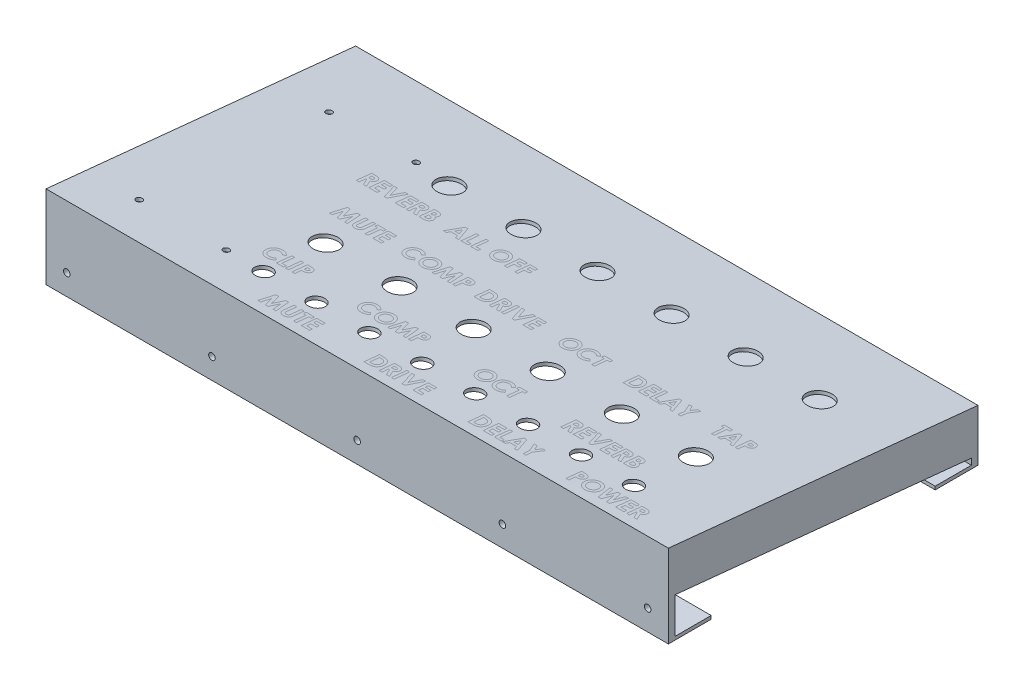
from build123d import *

# Parameters (mm, degrees)
BOSS_EXTRU_1_DEPTH      = 300
ESQUISSE3_W             = 300
ESQUISSE3_H             = 19.05
BOSS_EXTRU_2_DEPTH      = 1.5875
ESQUISSE4_W             = 300
ESQUISSE4_H             = 1.5875
BOSS_EXTRU_3_DEPTH      = 17.4625
ESQUISSE5_W             = 300
ESQUISSE5_H             = 19.05
BOSS_EXTRU_4_DEPTH      = 1.5875
ESQUISSE6_W             = 300
ESQUISSE6_H             = 1.5875
BOSS_EXTRU_5_DEPTH      = 17.4625
BOSS_EXTRU_6_DEPTH      = 19.05
BOSS_EXTRU_7_DEPTH      = 1.5875
BOSS_EXTRU_8_DEPTH      = 19.05
BOSS_EXTRU_9_DEPTH      = 1.5875
ESQUISSE12_R            = 1.5875
ENL_V_MAT_EXTRU_1_DEPTH = 150.248115566
ENL_V_MAT_EXTRU_2_REACH = 41.799
ESQUISSE13_R            = 4
ESQUISSE13_R_2          = 6
ESQUISSE13_R_3          = 1.5


with BuildPart() as part:
    # Esquisse1 → Boss.-Extru.1 (new body)
    with BuildSketch(Plane(origin=(0, 0, 0), x_dir=(0, 0, -1), z_dir=(1, 0, 0))):
        Polygon((-26.397970452, -24.428163497), (-26.397970452, 15.571836503), (122.850145114, 0.571836503), (122.850145114, -24.428163497), (121.262645114, -24.428163497), (121.262645114, -0.864111276), (-24.810470452, 13.816789218), (-24.810470452, -24.428163497), align=None)
    extrude(amount=BOSS_EXTRU_1_DEPTH)

    # Esquisse3 → Boss.-Extru.2 (add)
    with BuildSketch(Plane(origin=(0, 0, 24.810470452), x_dir=(-1, 0, 0), z_dir=(0, 0, -1))):
        with Locations((-150, -14.903163497)):
            Rectangle(ESQUISSE3_W, ESQUISSE3_H)
    extrude(amount=BOSS_EXTRU_2_DEPTH)

    # Esquisse4 → Boss.-Extru.3 (add)
    with BuildSketch(Plane(origin=(0, 0, 23.222970452), x_dir=(-1, 0, 0), z_dir=(0, 0, -1))):
        with Locations((-150, -23.634413497)):
            Rectangle(ESQUISSE4_W, ESQUISSE4_H)
    extrude(amount=BOSS_EXTRU_3_DEPTH)

    # Esquisse5 → Boss.-Extru.4 (add)
    with BuildSketch(Plane.XY.offset(-121.262645114)):
        with Locations((150, -14.903163497)):
            Rectangle(ESQUISSE5_W, ESQUISSE5_H)
    extrude(amount=BOSS_EXTRU_4_DEPTH)

    # Esquisse6 → Boss.-Extru.5 (add)
    with BuildSketch(Plane.XY.offset(-119.675145114)):
        with Locations((150, -23.634413497)):
            Rectangle(ESQUISSE6_W, ESQUISSE6_H)
    extrude(amount=BOSS_EXTRU_5_DEPTH)

    # Esquisse7 → Boss.-Extru.6 (add)
    with BuildSketch(Plane(origin=(300, 0, 0), x_dir=(0, 0, -1), z_dir=(1, 0, 0))):
        Polygon((-24.810470452, 13.816789218), (-24.810470452, 12.221291686), (121.262645114, -2.459608808), (121.262645114, -0.864111276), align=None)
    extrude(amount=-BOSS_EXTRU_6_DEPTH)

    # Esquisse8 → Boss.-Extru.7 (add)
    with BuildSketch(Plane(origin=(300, 0, 0), x_dir=(0, 0, -1), z_dir=(1, 0, 0))):
        Polygon((-24.810470452, 12.221291686), (121.262645114, -2.459608808), (121.262645114, -5.378163497), (119.675145114, -5.378163497), (119.675145114, -19.850531903), (-24.810470452, -5.329181163), align=None)
    extrude(amount=-BOSS_EXTRU_7_DEPTH)



with BuildPart() as body_2:
    # Esquisse9 → Boss.-Extru.8 (new body)
    with BuildSketch(Plane.ZY):
        Polygon((-121.262645114, -0.864111276), (24.810470452, 13.816789218), (24.810470452, 12.221291686), (-121.262645114, -2.459608808), align=None)
    extrude(amount=-BOSS_EXTRU_8_DEPTH)


with BuildPart() as part_1:
    add(part.part)

    add(body_2.part)  # Boss.-Extru.9 merges body 2
    # Esquisse11 → Boss.-Extru.9 (add)
    with BuildSketch(Plane.ZY):
        Polygon((-121.262645114, -2.459608808), (-121.262645114, -5.378163497), (-119.675145114, -5.378163497), (-119.675145114, -19.850531903), (24.810470452, -5.329181163), (24.810470452, 12.221291686), align=None)
    extrude(amount=-BOSS_EXTRU_9_DEPTH)

    # Esquisse12 → Enlèv. mat.-Extru.1 (cut, through all)
    with BuildSketch(Plane(origin=(0, 0, -122.850145114), x_dir=(-1, 0, 0), z_dir=(0, 0, -1))):
        with Locations((-290, -14.428163497)):
            Circle(ESQUISSE12_R)
        with Locations((-150, -14.428163497)):
            Circle(ESQUISSE12_R)
        with Locations((-10, -14.428163497)):
            Circle(ESQUISSE12_R)
        with Locations((-220, -14.428163497)):
            Circle(ESQUISSE12_R)
        with Locations((-80, -14.428163497)):
            Circle(ESQUISSE12_R)
    extrude(amount=-ENL_V_MAT_EXTRU_1_DEPTH, mode=Mode.SUBTRACT)

    # Esquisse13 → Enlèv. mat.-Extru.2 (cut, up to next)
    with BuildSketch(Plane(origin=(0, 12.789553241, -1.285398465), x_dir=(1, 0, 0), z_dir=(0, 0.994987437, -0.1)), mode=Mode.PRIVATE) as enl_v_mat_extru_2_sk1:
        with Locations((263.5, -7.822832615)):
            Circle(ESQUISSE13_R)
    enl_v_mat_extru_2_tool1 = extrude(enl_v_mat_extru_2_sk1.sketch, amount=-ENL_V_MAT_EXTRU_2_REACH, mode=Mode.PRIVATE) & part_1.part
    add(enl_v_mat_extru_2_tool1.solids().sort_by_distance((263.5, 13.571837, 6.498222))[0], mode=Mode.SUBTRACT)
    # Esquisse13 → Enlèv. mat.-Extru.2 (cut, up to next)
    with BuildSketch(Plane(origin=(0, 12.789553241, -1.285398465), x_dir=(1, 0, 0), z_dir=(0, 0.994987437, -0.1)), mode=Mode.PRIVATE) as enl_v_mat_extru_2_sk2:
        with Locations((238, -7.822832615)):
            Circle(ESQUISSE13_R)
    enl_v_mat_extru_2_tool2 = extrude(enl_v_mat_extru_2_sk2.sketch, amount=-ENL_V_MAT_EXTRU_2_REACH, mode=Mode.PRIVATE) & part_1.part
    add(enl_v_mat_extru_2_tool2.solids().sort_by_distance((238, 13.571837, 6.498222))[0], mode=Mode.SUBTRACT)
    # Esquisse13 → Enlèv. mat.-Extru.2 (cut, up to next)
    with BuildSketch(Plane(origin=(0, 12.789553241, -1.285398465), x_dir=(1, 0, 0), z_dir=(0, 0.994987437, -0.1)), mode=Mode.PRIVATE) as enl_v_mat_extru_2_sk3:
        with Locations((212.5, -7.822832615)):
            Circle(ESQUISSE13_R)
    enl_v_mat_extru_2_tool3 = extrude(enl_v_mat_extru_2_sk3.sketch, amount=-ENL_V_MAT_EXTRU_2_REACH, mode=Mode.PRIVATE) & part_1.part
    add(enl_v_mat_extru_2_tool3.solids().sort_by_distance((212.5, 13.571837, 6.498222))[0], mode=Mode.SUBTRACT)
    # Esquisse13 → Enlèv. mat.-Extru.2 (cut, up to next)
    with BuildSketch(Plane(origin=(0, 12.789553241, -1.285398465), x_dir=(1, 0, 0), z_dir=(0, 0.994987437, -0.1)), mode=Mode.PRIVATE) as enl_v_mat_extru_2_sk4:
        with Locations((187, -7.822832615)):
            Circle(ESQUISSE13_R)
    enl_v_mat_extru_2_tool4 = extrude(enl_v_mat_extru_2_sk4.sketch, amount=-ENL_V_MAT_EXTRU_2_REACH, mode=Mode.PRIVATE) & part_1.part
    add(enl_v_mat_extru_2_tool4.solids().sort_by_distance((187, 13.571837, 6.498222))[0], mode=Mode.SUBTRACT)
    # Esquisse13 → Enlèv. mat.-Extru.2 (cut, up to next)
    with BuildSketch(Plane(origin=(0, 12.789553241, -1.285398465), x_dir=(1, 0, 0), z_dir=(0, 0.994987437, -0.1)), mode=Mode.PRIVATE) as enl_v_mat_extru_2_sk5:
        with Locations((161.5, -7.822832615)):
            Circle(ESQUISSE13_R)
    enl_v_mat_extru_2_tool5 = extrude(enl_v_mat_extru_2_sk5.sketch, amount=-ENL_V_MAT_EXTRU_2_REACH, mode=Mode.PRIVATE) & part_1.part
    add(enl_v_mat_extru_2_tool5.solids().sort_by_distance((161.5, 13.571837, 6.498222))[0], mode=Mode.SUBTRACT)
    # Esquisse13 → Enlèv. mat.-Extru.2 (cut, up to next)
    with BuildSketch(Plane(origin=(0, 12.789553241, -1.285398465), x_dir=(1, 0, 0), z_dir=(0, 0.994987437, -0.1)), mode=Mode.PRIVATE) as enl_v_mat_extru_2_sk6:
        with Locations((136, -7.822832615)):
            Circle(ESQUISSE13_R)
    enl_v_mat_extru_2_tool6 = extrude(enl_v_mat_extru_2_sk6.sketch, amount=-ENL_V_MAT_EXTRU_2_REACH, mode=Mode.PRIVATE) & part_1.part
    add(enl_v_mat_extru_2_tool6.solids().sort_by_distance((136, 13.571837, 6.498222))[0], mode=Mode.SUBTRACT)
    # Esquisse13 → Enlèv. mat.-Extru.2 (cut, up to next)
    with BuildSketch(Plane(origin=(0, 12.789553241, -1.285398465), x_dir=(1, 0, 0), z_dir=(0, 0.994987437, -0.1)), mode=Mode.PRIVATE) as enl_v_mat_extru_2_sk7:
        with Locations((110.5, -7.822832615)):
            Circle(ESQUISSE13_R)
    enl_v_mat_extru_2_tool7 = extrude(enl_v_mat_extru_2_sk7.sketch, amount=-ENL_V_MAT_EXTRU_2_REACH, mode=Mode.PRIVATE) & part_1.part
    add(enl_v_mat_extru_2_tool7.solids().sort_by_distance((110.5, 13.571837, 6.498222))[0], mode=Mode.SUBTRACT)
    # Esquisse13 → Enlèv. mat.-Extru.2 (cut, up to next)
    with BuildSketch(Plane(origin=(0, 12.789553241, -1.285398465), x_dir=(1, 0, 0), z_dir=(0, 0.994987437, -0.1)), mode=Mode.PRIVATE) as enl_v_mat_extru_2_sk8:
        with Locations((85, -7.822832615)):
            Circle(ESQUISSE13_R)
    enl_v_mat_extru_2_tool8 = extrude(enl_v_mat_extru_2_sk8.sketch, amount=-ENL_V_MAT_EXTRU_2_REACH, mode=Mode.PRIVATE) & part_1.part
    add(enl_v_mat_extru_2_tool8.solids().sort_by_distance((85, 13.571837, 6.498222))[0], mode=Mode.SUBTRACT)
    # Esquisse13 → Enlèv. mat.-Extru.2 (cut, up to next)
    with BuildSketch(Plane(origin=(0, 12.789553241, -1.285398465), x_dir=(1, 0, 0), z_dir=(0, 0.994987437, -0.1)), mode=Mode.PRIVATE) as enl_v_mat_extru_2_sk9:
        with Locations((263.5, 22.177167385)):
            Circle(ESQUISSE13_R_2)
    enl_v_mat_extru_2_tool9 = extrude(enl_v_mat_extru_2_sk9.sketch, amount=-ENL_V_MAT_EXTRU_2_REACH, mode=Mode.PRIVATE) & part_1.part
    add(enl_v_mat_extru_2_tool9.solids().sort_by_distance((263.5, 10.571837, -23.351401))[0], mode=Mode.SUBTRACT)
    # Esquisse13 → Enlèv. mat.-Extru.2 (cut, up to next)
    with BuildSketch(Plane(origin=(0, 12.789553241, -1.285398465), x_dir=(1, 0, 0), z_dir=(0, 0.994987437, -0.1)), mode=Mode.PRIVATE) as enl_v_mat_extru_2_sk10:
        with Locations((227.8, 22.177167385)):
            Circle(ESQUISSE13_R_2)
    enl_v_mat_extru_2_tool10 = extrude(enl_v_mat_extru_2_sk10.sketch, amount=-ENL_V_MAT_EXTRU_2_REACH, mode=Mode.PRIVATE) & part_1.part
    add(enl_v_mat_extru_2_tool10.solids().sort_by_distance((227.8, 10.571837, -23.351401))[0], mode=Mode.SUBTRACT)
    # Esquisse13 → Enlèv. mat.-Extru.2 (cut, up to next)
    with BuildSketch(Plane(origin=(0, 12.789553241, -1.285398465), x_dir=(1, 0, 0), z_dir=(0, 0.994987437, -0.1)), mode=Mode.PRIVATE) as enl_v_mat_extru_2_sk11:
        with Locations((192.1, 22.177167385)):
            Circle(ESQUISSE13_R_2)
    enl_v_mat_extru_2_tool11 = extrude(enl_v_mat_extru_2_sk11.sketch, amount=-ENL_V_MAT_EXTRU_2_REACH, mode=Mode.PRIVATE) & part_1.part
    add(enl_v_mat_extru_2_tool11.solids().sort_by_distance((192.1, 10.571837, -23.351401))[0], mode=Mode.SUBTRACT)
    # Esquisse13 → Enlèv. mat.-Extru.2 (cut, up to next)
    with BuildSketch(Plane(origin=(0, 12.789553241, -1.285398465), x_dir=(1, 0, 0), z_dir=(0, 0.994987437, -0.1)), mode=Mode.PRIVATE) as enl_v_mat_extru_2_sk12:
        with Locations((156.4, 22.177167385)):
            Circle(ESQUISSE13_R_2)
    enl_v_mat_extru_2_tool12 = extrude(enl_v_mat_extru_2_sk12.sketch, amount=-ENL_V_MAT_EXTRU_2_REACH, mode=Mode.PRIVATE) & part_1.part
    add(enl_v_mat_extru_2_tool12.solids().sort_by_distance((156.4, 10.571837, -23.351401))[0], mode=Mode.SUBTRACT)
    # Esquisse13 → Enlèv. mat.-Extru.2 (cut, up to next)
    with BuildSketch(Plane(origin=(0, 12.789553241, -1.285398465), x_dir=(1, 0, 0), z_dir=(0, 0.994987437, -0.1)), mode=Mode.PRIVATE) as enl_v_mat_extru_2_sk13:
        with Locations((120.7, 22.177167385)):
            Circle(ESQUISSE13_R_2)
    enl_v_mat_extru_2_tool13 = extrude(enl_v_mat_extru_2_sk13.sketch, amount=-ENL_V_MAT_EXTRU_2_REACH, mode=Mode.PRIVATE) & part_1.part
    add(enl_v_mat_extru_2_tool13.solids().sort_by_distance((120.7, 10.571837, -23.351401))[0], mode=Mode.SUBTRACT)
    # Esquisse13 → Enlèv. mat.-Extru.2 (cut, up to next)
    with BuildSketch(Plane(origin=(0, 12.789553241, -1.285398465), x_dir=(1, 0, 0), z_dir=(0, 0.994987437, -0.1)), mode=Mode.PRIVATE) as enl_v_mat_extru_2_sk14:
        with Locations((85, 22.177167385)):
            Circle(ESQUISSE13_R_2)
    enl_v_mat_extru_2_tool14 = extrude(enl_v_mat_extru_2_sk14.sketch, amount=-ENL_V_MAT_EXTRU_2_REACH, mode=Mode.PRIVATE) & part_1.part
    add(enl_v_mat_extru_2_tool14.solids().sort_by_distance((85, 10.571837, -23.351401))[0], mode=Mode.SUBTRACT)
    # Esquisse13 → Enlèv. mat.-Extru.2 (cut, up to next)
    with BuildSketch(Plane(origin=(0, 12.789553241, -1.285398465), x_dir=(1, 0, 0), z_dir=(0, 0.994987437, -0.1)), mode=Mode.PRIVATE) as enl_v_mat_extru_2_sk15:
        with Locations((227.8, 82.177167385)):
            Circle(ESQUISSE13_R_2)
    enl_v_mat_extru_2_tool15 = extrude(enl_v_mat_extru_2_sk15.sketch, amount=-ENL_V_MAT_EXTRU_2_REACH, mode=Mode.PRIVATE) & part_1.part
    add(enl_v_mat_extru_2_tool15.solids().sort_by_distance((227.8, 4.571837, -83.050648))[0], mode=Mode.SUBTRACT)
    # Esquisse13 → Enlèv. mat.-Extru.2 (cut, up to next)
    with BuildSketch(Plane(origin=(0, 12.789553241, -1.285398465), x_dir=(1, 0, 0), z_dir=(0, 0.994987437, -0.1)), mode=Mode.PRIVATE) as enl_v_mat_extru_2_sk16:
        with Locations((192.1, 82.177167385)):
            Circle(ESQUISSE13_R_2)
    enl_v_mat_extru_2_tool16 = extrude(enl_v_mat_extru_2_sk16.sketch, amount=-ENL_V_MAT_EXTRU_2_REACH, mode=Mode.PRIVATE) & part_1.part
    add(enl_v_mat_extru_2_tool16.solids().sort_by_distance((192.1, 4.571837, -83.050648))[0], mode=Mode.SUBTRACT)
    # Esquisse13 → Enlèv. mat.-Extru.2 (cut, up to next)
    with BuildSketch(Plane(origin=(0, 12.789553241, -1.285398465), x_dir=(1, 0, 0), z_dir=(0, 0.994987437, -0.1)), mode=Mode.PRIVATE) as enl_v_mat_extru_2_sk17:
        with Locations((156.4, 82.177167385)):
            Circle(ESQUISSE13_R_2)
    enl_v_mat_extru_2_tool17 = extrude(enl_v_mat_extru_2_sk17.sketch, amount=-ENL_V_MAT_EXTRU_2_REACH, mode=Mode.PRIVATE) & part_1.part
    add(enl_v_mat_extru_2_tool17.solids().sort_by_distance((156.4, 4.571837, -83.050648))[0], mode=Mode.SUBTRACT)
    # Esquisse13 → Enlèv. mat.-Extru.2 (cut, up to next)
    with BuildSketch(Plane(origin=(0, 12.789553241, -1.285398465), x_dir=(1, 0, 0), z_dir=(0, 0.994987437, -0.1)), mode=Mode.PRIVATE) as enl_v_mat_extru_2_sk18:
        with Locations((120.7, 82.177167385)):
            Circle(ESQUISSE13_R_2)
    enl_v_mat_extru_2_tool18 = extrude(enl_v_mat_extru_2_sk18.sketch, amount=-ENL_V_MAT_EXTRU_2_REACH, mode=Mode.PRIVATE) & part_1.part
    add(enl_v_mat_extru_2_tool18.solids().sort_by_distance((120.7, 4.571837, -83.050648))[0], mode=Mode.SUBTRACT)
    # Esquisse13 → Enlèv. mat.-Extru.2 (cut, up to next)
    with BuildSketch(Plane(origin=(0, 12.789553241, -1.285398465), x_dir=(1, 0, 0), z_dir=(0, 0.994987437, -0.1)), mode=Mode.PRIVATE) as enl_v_mat_extru_2_sk19:
        with Locations((85, 82.177167385)):
            Circle(ESQUISSE13_R_2)
    enl_v_mat_extru_2_tool19 = extrude(enl_v_mat_extru_2_sk19.sketch, amount=-ENL_V_MAT_EXTRU_2_REACH, mode=Mode.PRIVATE) & part_1.part
    add(enl_v_mat_extru_2_tool19.solids().sort_by_distance((85, 4.571837, -83.050648))[0], mode=Mode.SUBTRACT)
    # Esquisse13 → Enlèv. mat.-Extru.2 (cut, up to next)
    with BuildSketch(Plane(origin=(0, 12.789553241, -1.285398465), x_dir=(1, 0, 0), z_dir=(0, 0.994987437, -0.1)), mode=Mode.PRIVATE) as enl_v_mat_extru_2_sk20:
        with Locations((263.5, 82.177167385)):
            Circle(ESQUISSE13_R_2)
    enl_v_mat_extru_2_tool20 = extrude(enl_v_mat_extru_2_sk20.sketch, amount=-ENL_V_MAT_EXTRU_2_REACH, mode=Mode.PRIVATE) & part_1.part
    add(enl_v_mat_extru_2_tool20.solids().sort_by_distance((263.5, 4.571837, -83.050648))[0], mode=Mode.SUBTRACT)
    # Esquisse13 → Enlèv. mat.-Extru.2 (cut, up to next)
    with BuildSketch(Plane(origin=(0, 12.789553241, -1.285398465), x_dir=(1, 0, 0), z_dir=(0, 0.994987437, -0.1)), mode=Mode.PRIVATE) as enl_v_mat_extru_2_sk21:
        with Locations((67, -7.822832615)):
            Circle(ESQUISSE13_R_3)
    enl_v_mat_extru_2_tool21 = extrude(enl_v_mat_extru_2_sk21.sketch, amount=-ENL_V_MAT_EXTRU_2_REACH, mode=Mode.PRIVATE) & part_1.part
    add(enl_v_mat_extru_2_tool21.solids().sort_by_distance((67, 13.571837, 6.498222))[0], mode=Mode.SUBTRACT)
    # Esquisse13 → Enlèv. mat.-Extru.2 (cut, up to next)
    with BuildSketch(Plane(origin=(0, 12.789553241, -1.285398465), x_dir=(1, 0, 0), z_dir=(0, 0.994987437, -0.1)), mode=Mode.PRIVATE) as enl_v_mat_extru_2_sk22:
        with Locations((25, -7.822832615)):
            Circle(ESQUISSE13_R_3)
    enl_v_mat_extru_2_tool22 = extrude(enl_v_mat_extru_2_sk22.sketch, amount=-ENL_V_MAT_EXTRU_2_REACH, mode=Mode.PRIVATE) & part_1.part
    add(enl_v_mat_extru_2_tool22.solids().sort_by_distance((25, 13.571837, 6.498222))[0], mode=Mode.SUBTRACT)
    # Esquisse13 → Enlèv. mat.-Extru.2 (cut, up to next)
    with BuildSketch(Plane(origin=(0, 12.789553241, -1.285398465), x_dir=(1, 0, 0), z_dir=(0, 0.994987437, -0.1)), mode=Mode.PRIVATE) as enl_v_mat_extru_2_sk23:
        with Locations((67, 84.177167385)):
            Circle(ESQUISSE13_R_3)
    enl_v_mat_extru_2_tool23 = extrude(enl_v_mat_extru_2_sk23.sketch, amount=-ENL_V_MAT_EXTRU_2_REACH, mode=Mode.PRIVATE) & part_1.part
    add(enl_v_mat_extru_2_tool23.solids().sort_by_distance((67, 4.371837, -85.040623))[0], mode=Mode.SUBTRACT)
    # Esquisse13 → Enlèv. mat.-Extru.2 (cut, up to next)
    with BuildSketch(Plane(origin=(0, 12.789553241, -1.285398465), x_dir=(1, 0, 0), z_dir=(0, 0.994987437, -0.1)), mode=Mode.PRIVATE) as enl_v_mat_extru_2_sk24:
        with Locations((25, 84.177167385)):
            Circle(ESQUISSE13_R_3)
    enl_v_mat_extru_2_tool24 = extrude(enl_v_mat_extru_2_sk24.sketch, amount=-ENL_V_MAT_EXTRU_2_REACH, mode=Mode.PRIVATE) & part_1.part
    add(enl_v_mat_extru_2_tool24.solids().sort_by_distance((25, 4.371837, -85.040623))[0], mode=Mode.SUBTRACT)


solid = part_1.part
